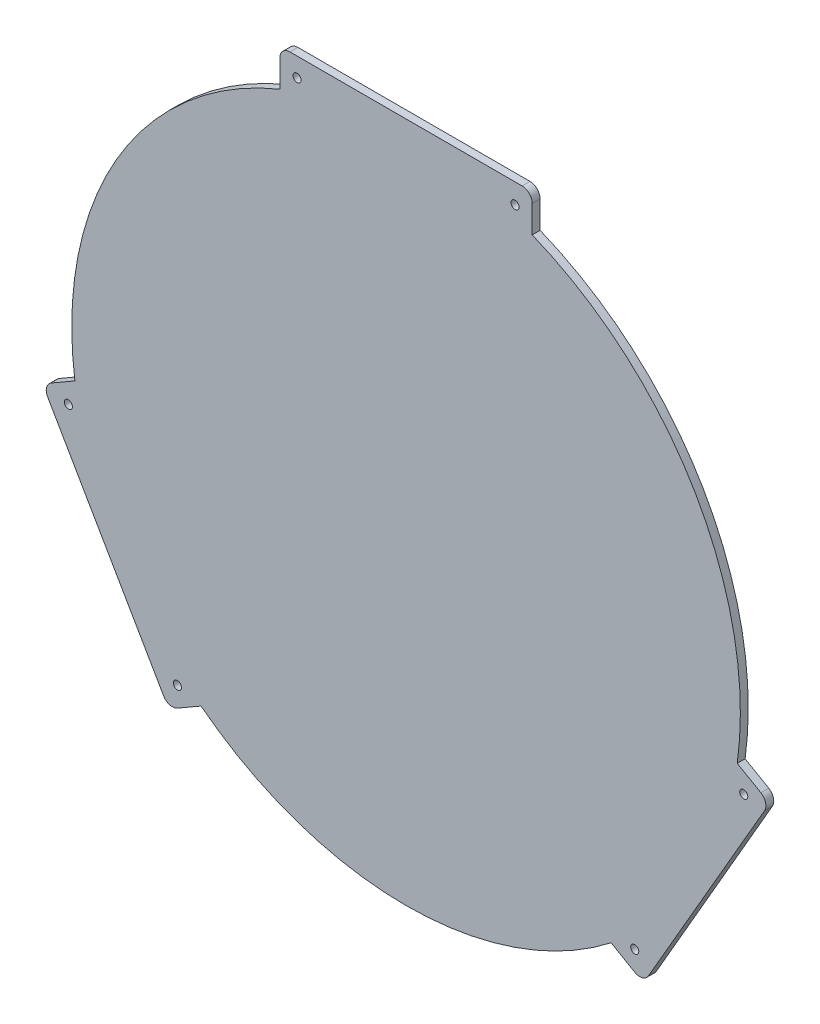
from build123d import *

# Parameters (mm, degrees)
MODEL_R             = 1.6
BOSS_EXTRUDE1_DEPTH = 3.125


with BuildPart() as part:
    # Model → Boss-Extrude1 (new body)
    with BuildSketch(Plane.XY):
        with BuildLine():
            Line((194.5, 257.413429511), (102.5, 257.413429511))
            ThreePointArc((102.5, 257.413429511), (99.671572875, 256.241856636), (98.5, 253.413429511))
            Line((98.5, 253.413429511), (98.5, 242.617341429))
            ThreePointArc((98.5, 242.617341429), (33.751633999, 186.163429511), (17.235295135, 101.862743741))
            Line((17.235295135, 101.862743741), (7.885608595, 96.4646997))
            ThreePointArc((7.885608595, 96.4646997), (6.02190529, 94.035874265), (6.42150698, 91.000598085))
            Line((6.42150698, 91.000598085), (52.42150698, 11.326260937))
            ThreePointArc((52.42150698, 11.326260937), (54.850332414, 9.462557632), (57.885608595, 9.862159322))
            Line((57.885608595, 9.862159322), (67.235295135, 15.260203363))
            ThreePointArc((67.235295135, 15.260203363), (148.5, -12.586570489), (229.764704865, 15.260203363))
            Line((229.764704865, 15.260203363), (239.114391405, 9.862159322))
            ThreePointArc((239.114391405, 9.862159322), (242.149667586, 9.462557632), (244.57849302, 11.326260937))
            Line((244.57849302, 11.326260937), (290.57849302, 91.000598085))
            ThreePointArc((290.57849302, 91.000598085), (290.97809471, 94.035874265), (289.114391405, 96.4646997))
            Line((289.114391405, 96.4646997), (279.764704865, 101.862743741))
            ThreePointArc((279.764704865, 101.862743741), (263.248366001, 186.163429511), (198.5, 242.617341429))
            Line((198.5, 242.617341429), (198.5, 253.413429511))
            ThreePointArc((198.5, 253.413429511), (197.328427125, 256.241856636), (194.5, 257.413429511))
        make_face()
        with Locations((105.3, 249.913429511)):
            Circle(MODEL_R, mode=Mode.SUBTRACT)
        with Locations((191.7, 249.513429511)):
            Circle(MODEL_R, mode=Mode.SUBTRACT)
        with Locations((282.33689233, 92.525726954)):
            Circle(MODEL_R, mode=Mode.SUBTRACT)
        with Locations((239.13689233, 17.701132067)):
            Circle(MODEL_R, mode=Mode.SUBTRACT)
        with Locations((14.66310767, 92.525726954)):
            Circle(MODEL_R, mode=Mode.SUBTRACT)
        with Locations((57.86310767, 17.701132067)):
            Circle(MODEL_R, mode=Mode.SUBTRACT)
    extrude(amount=BOSS_EXTRUDE1_DEPTH)


solid = part.part
